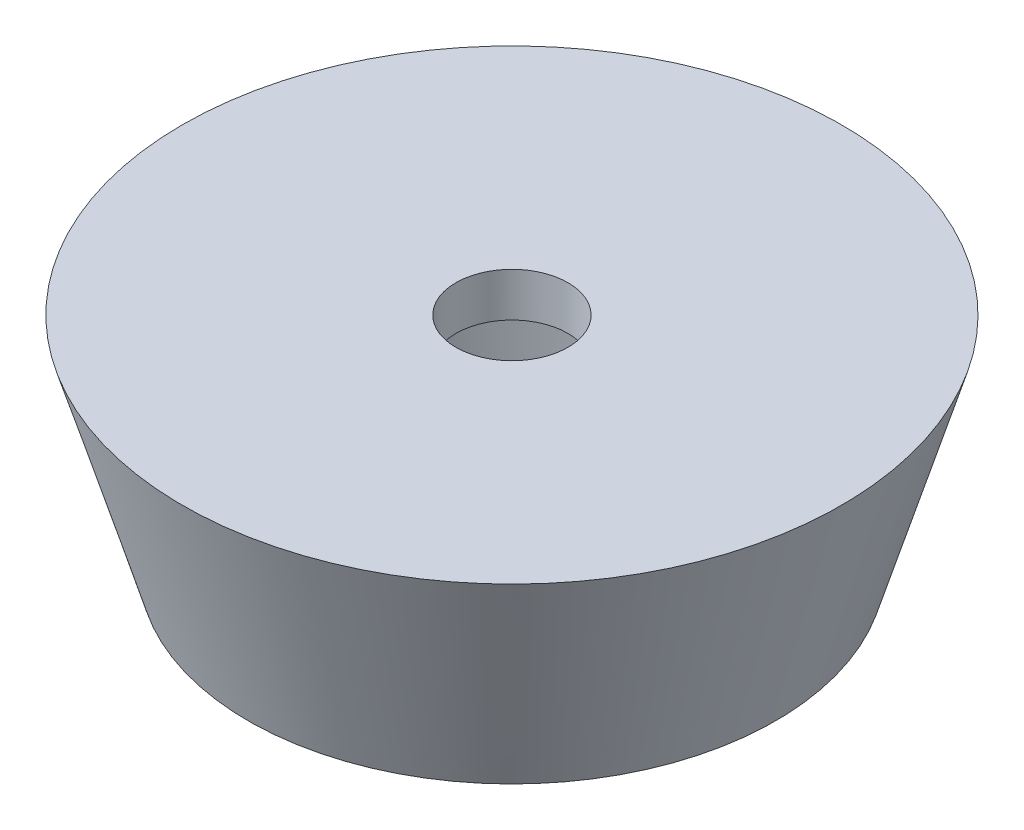
from build123d import *

# Parameters (mm, degrees)
CROQUIS2_R            = 2.55
CORTAR_EXTRUIR1_DEPTH = 10
CROQUIS3_R            = 10
CORTAR_EXTRUIR2_DEPTH = 8


with BuildPart() as part:
    # Croquis1 → Revolución1 (revolve)
    with BuildSketch(Plane.XY):
        Polygon((-12.044691582, 0), (-15, 0), (-12, -10), (0, -10), (0, 0), align=None)
    revolve(axis=Axis((0, 0, 0), (0, -1, 0)))

    # Croquis2 → Cortar-Extruir1 (cut)
    with BuildSketch(Plane(origin=(0, 0, 0), x_dir=(1, 0, 0), z_dir=(0, 1, 0))):
        Circle(CROQUIS2_R)
    extrude(amount=-CORTAR_EXTRUIR1_DEPTH, mode=Mode.SUBTRACT)

    # Croquis3 → Cortar-Extruir2 (cut)
    with BuildSketch(Plane(origin=(0, -10, 0), x_dir=(-1, 0, 0), z_dir=(0, -1, 0))):
        Circle(CROQUIS3_R)
    extrude(amount=-CORTAR_EXTRUIR2_DEPTH, mode=Mode.SUBTRACT)


solid = part.part
